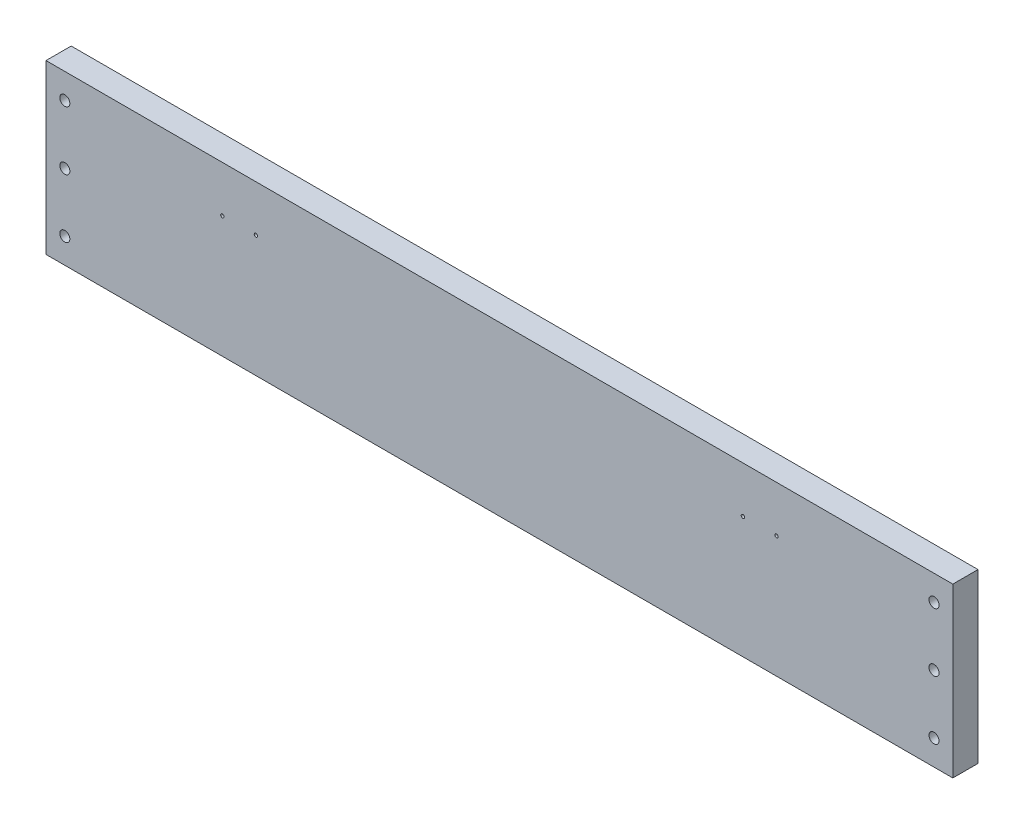
from build123d import *

# Parameters (mm, degrees)
SKETCH3_W           = 647.7
SKETCH3_H           = 19.05
SKETCH3_W_2         = 19.05
BOSS_EXTRUDE1_DEPTH = 127
SKETCH4_R           = 3.81
CUT_EXTRUDE1_DEPTH  = 19.05
SKETCH5_R           = 1.27
CUT_EXTRUDE2_DEPTH  = 114.3


with BuildPart() as part:
    # Sketch3 → Boss-Extrude1 (new body)
    with BuildSketch(Plane(origin=(0, 0, 0), x_dir=(1, 0, 0), z_dir=(0, 1, 0))):
        with Locations((342.9, 9.525)):
            Rectangle(SKETCH3_W, SKETCH3_H)
        with Locations((9.525, 9.525)):
            Rectangle(SKETCH3_W_2, SKETCH3_H)
        with Locations((676.275, 9.525)):
            Rectangle(SKETCH3_W_2, SKETCH3_H)
    extrude(amount=BOSS_EXTRUDE1_DEPTH)

    # Sketch4 → Cut-Extrude1 (cut)
    with BuildSketch(Plane.XY):
        with Locations((671.576, 107.95)):
            Circle(SKETCH4_R)
        with Locations((671.576, 63.5)):
            Circle(SKETCH4_R)
        with Locations((671.576, 19.05)):
            Circle(SKETCH4_R)
        with Locations((14.224, 63.5)):
            Circle(SKETCH4_R)
        with Locations((14.224, 107.95)):
            Circle(SKETCH4_R)
        with Locations((14.224, 19.05)):
            Circle(SKETCH4_R)
    extrude(amount=-CUT_EXTRUDE1_DEPTH, mode=Mode.SUBTRACT)

    # Sketch5 → Cut-Extrude2 (cut)
    with BuildSketch(Plane.XY):
        with Locations((133.35, 91.948)):
            Circle(SKETCH5_R)
        with Locations((158.75, 91.948)):
            Circle(SKETCH5_R)
        with Locations((527.05, 91.948)):
            Circle(SKETCH5_R)
        with Locations((552.45, 91.948)):
            Circle(SKETCH5_R)
    extrude(amount=-CUT_EXTRUDE2_DEPTH, mode=Mode.SUBTRACT)


solid = part.part
